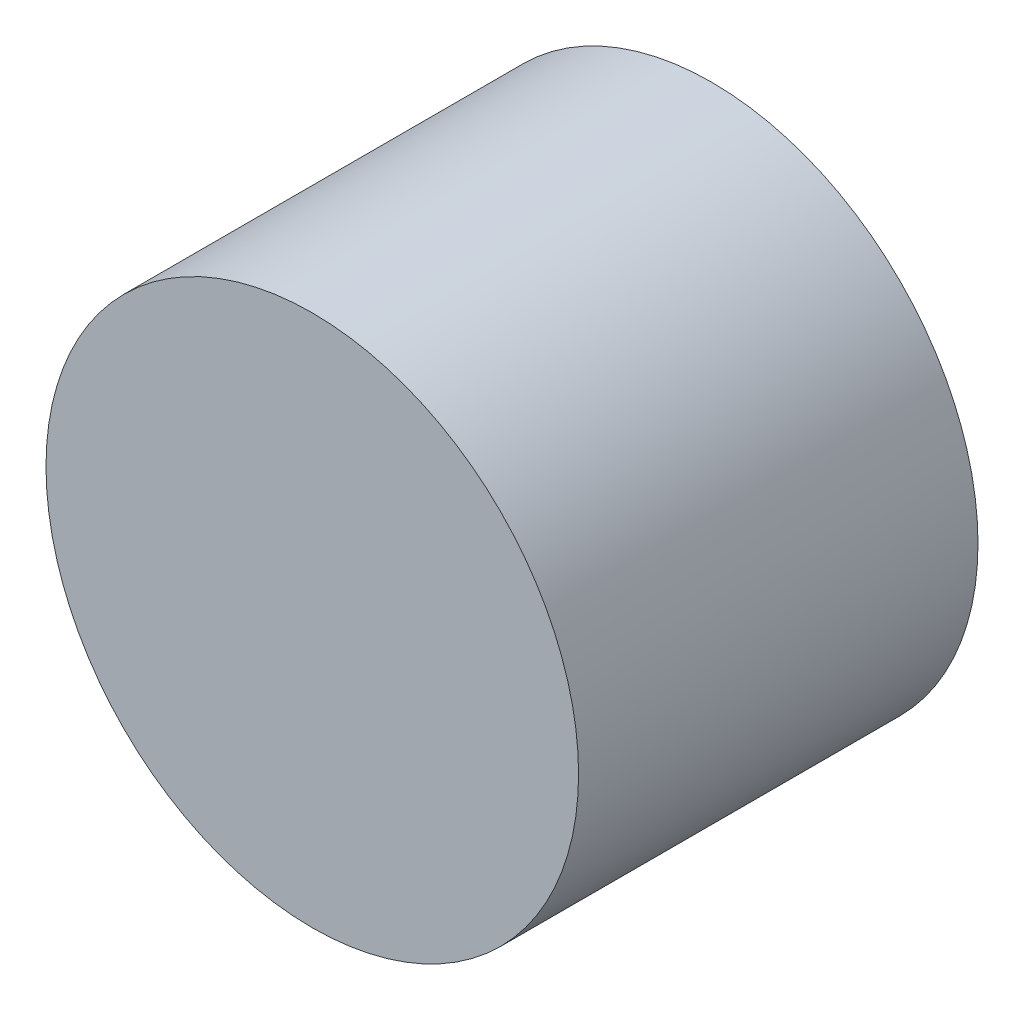
from build123d import *

# Parameters (mm, degrees)
SKETCH_1_R          = 4
EXTRUDE_1_DEPTH     = 6
CUT_EXTRUDE_1_DEPTH = 3


with BuildPart() as part:
    # 草图1 → 凸台-拉伸1 (new body)
    with BuildSketch(Plane.XY):
        Circle(SKETCH_1_R)
    extrude(amount=EXTRUDE_1_DEPTH)

    # 草图3 → 切除-拉伸1 (cut)
    with BuildSketch(Plane(origin=(0, 0, 0), x_dir=(-1, 0, 0), z_dir=(0, 0, -1))):
        Polygon((2.998599074, -0.091671127), (1.578689062, 2.55102741), (-1.419910012, 2.642698537), (-2.998599074, 0.091671127), (-1.578689062, -2.55102741), (1.419910012, -2.642698537), align=None)
    extrude(amount=-CUT_EXTRUDE_1_DEPTH, mode=Mode.SUBTRACT)


solid = part.part
